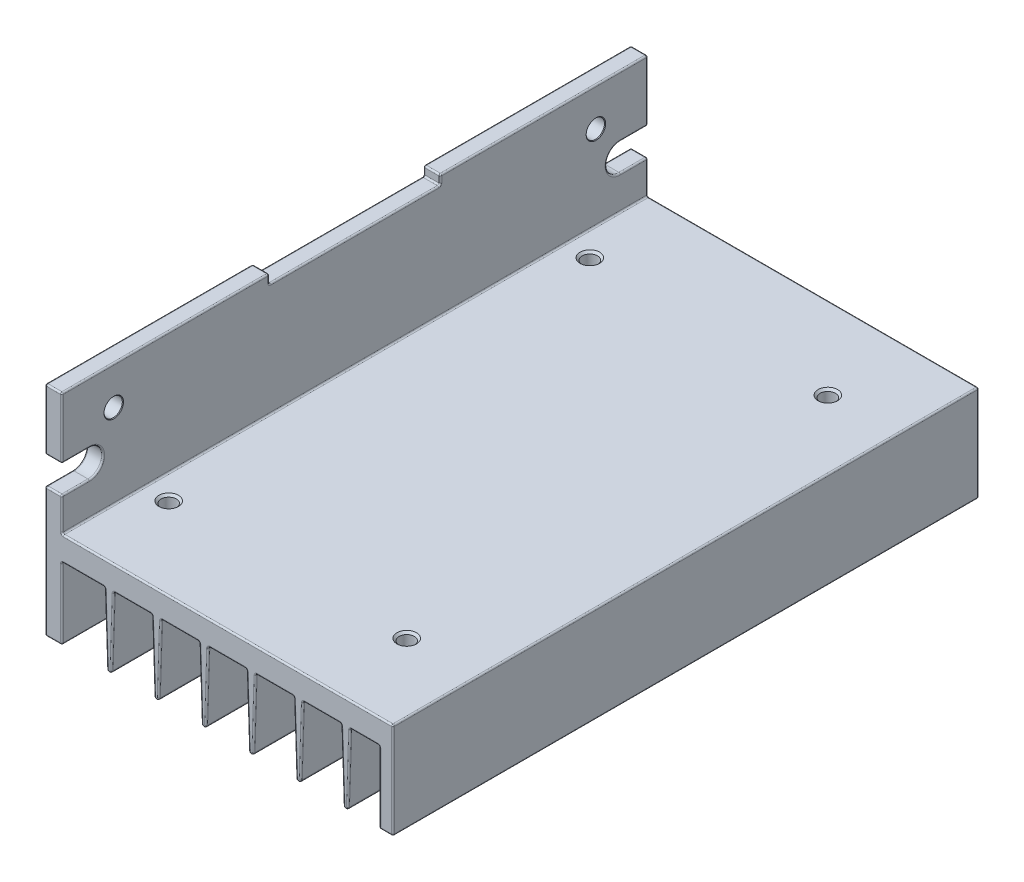
from build123d import *

# Parameters (mm, degrees)
BODY_DEPTH                  = 48
TOP_CUT_OUT_SKETCH_W        = 28
TOP_CUT_OUT_SKETCH_H        = 28
TOP_CUT_OUT_DEPTH           = 1.5
SIDE_CUT_OUT_DEPTH          = 3.75
M3_TOP_HOLES_AT_2_COUNT     = 2
M3_TOP_HOLES_AT_2_PITCH     = 69
M3_TOP_HOLES_AT_3_COUNT     = 2
M3_TOP_HOLES_AT_3_PITCH     = 79.259068882
M3_TOP_HOLES_AT_4_COUNT     = 2
M3_TOP_HOLES_AT_4_PITCH     = 39
F_3_0_SIDE_HOLES_AT_2_COUNT = 2
F_3_0_SIDE_HOLES_AT_2_PITCH = 79
PRODUCTION_FILLET_R         = 0.25


with BuildPart() as part:
    # Body Profile Sketch → Body (new body, symmetric)
    with BuildSketch(Plane.XY):
        with BuildLine():
            Line((0.25, 0), (54, 0))
            ThreePointArc((54, 0), (54.176776695, -0.073223305), (54.25, -0.25))
            Line((54.25, -0.25), (54.25, -15.5))
            ThreePointArc((54.25, -15.5), (54.176776695, -15.676776695), (54, -15.75))
            Line((54, -15.75), (52.25, -15.75))
            ThreePointArc((52.25, -15.75), (52.073223305, -15.676776695), (52, -15.5))
            Line((52, -15.5), (52, -4.25))
            ThreePointArc((52, -4.25), (51.926776695, -4.073223305), (51.75, -4))
            Line((51.75, -4), (47.491898383, -4))
            ThreePointArc((47.491898383, -4), (47.318056795, -4.070336141), (47.242033979, -4.241767182))
            Line((47.242033979, -4.241767182), (46.874796607, -15.387349227))
            ThreePointArc((46.874796607, -15.387349227), (46.5, -15.75), (46.125203393, -15.387349227))
            Line((46.125203393, -15.387349227), (45.757966021, -4.241767182))
            ThreePointArc((45.757966021, -4.241767182), (45.681943205, -4.070336141), (45.508101617, -4))
            Line((45.508101617, -4), (39.741898383, -4))
            ThreePointArc((39.741898383, -4), (39.568056795, -4.070336141), (39.492033979, -4.241767182))
            Line((39.492033979, -4.241767182), (39.124796607, -15.387349227))
            ThreePointArc((39.124796607, -15.387349227), (38.75, -15.75), (38.375203393, -15.387349227))
            Line((38.375203393, -15.387349227), (38.007966021, -4.241767182))
            ThreePointArc((38.007966021, -4.241767182), (37.931943205, -4.070336141), (37.758101617, -4))
            Line((37.758101617, -4), (31.991898383, -4))
            ThreePointArc((31.991898383, -4), (31.818056795, -4.070336141), (31.742033979, -4.241767182))
            Line((31.742033979, -4.241767182), (31.374796607, -15.387349227))
            ThreePointArc((31.374796607, -15.387349227), (31, -15.75), (30.625203393, -15.387349227))
            Line((30.625203393, -15.387349227), (30.257966021, -4.241767182))
            ThreePointArc((30.257966021, -4.241767182), (30.181943205, -4.070336141), (30.008101617, -4))
            Line((30.008101617, -4), (24.241898383, -4))
            ThreePointArc((24.241898383, -4), (24.068056795, -4.070336141), (23.992033979, -4.241767182))
            Line((23.992033979, -4.241767182), (23.624796607, -15.387349227))
            ThreePointArc((23.624796607, -15.387349227), (23.25, -15.75), (22.875203393, -15.387349227))
            Line((22.875203393, -15.387349227), (22.507966021, -4.241767182))
            ThreePointArc((22.507966021, -4.241767182), (22.431943205, -4.070336141), (22.258101617, -4))
            Line((22.258101617, -4), (16.491898383, -4))
            ThreePointArc((16.491898383, -4), (16.318056795, -4.070336141), (16.242033979, -4.241767182))
            Line((16.242033979, -4.241767182), (15.874796607, -15.387349227))
            ThreePointArc((15.874796607, -15.387349227), (15.5, -15.75), (15.125203393, -15.387349227))
            Line((15.125203393, -15.387349227), (14.757966021, -4.241767182))
            ThreePointArc((14.757966021, -4.241767182), (14.681943205, -4.070336141), (14.508101617, -4))
            Line((14.508101617, -4), (8.741898383, -4))
            ThreePointArc((8.741898383, -4), (8.568056795, -4.070336141), (8.492033979, -4.241767182))
            Line((8.492033979, -4.241767182), (8.124796607, -15.387349227))
            ThreePointArc((8.124796607, -15.387349227), (7.75, -15.75), (7.375203393, -15.387349227))
            Line((7.375203393, -15.387349227), (7.007966021, -4.241767182))
            ThreePointArc((7.007966021, -4.241767182), (6.931943205, -4.070336141), (6.758101617, -4))
            Line((6.758101617, -4), (0.25, -4))
            ThreePointArc((0.25, -4), (0.073223305, -4.073223305), (0, -4.25))
            Line((0, -4.25), (0, -15.5))
            ThreePointArc((0, -15.5), (-0.073223305, -15.676776695), (-0.25, -15.75))
            Line((-0.25, -15.75), (-2.5, -15.75))
            ThreePointArc((-2.5, -15.75), (-2.676776695, -15.676776695), (-2.75, -15.5))
            Line((-2.75, -15.5), (-2.75, 19.75))
            ThreePointArc((-2.75, 19.75), (-2.676776695, 19.926776695), (-2.5, 20))
            Line((-2.5, 20), (-0.25, 20))
            ThreePointArc((-0.25, 20), (-0.073223305, 19.926776695), (0, 19.75))
            Line((0, 19.75), (0, 0.25))
            ThreePointArc((0, 0.25), (0.073223305, 0.073223305), (0.25, 0))
        make_face()
    extrude(amount=BODY_DEPTH, both=True)

    # Top Cut Out Sketch → Top Cut Out (cut)
    with BuildSketch(Plane(origin=(0, 20, 0), x_dir=(1, 0, 0), z_dir=(0, 1, 0))):
        Rectangle(TOP_CUT_OUT_SKETCH_W, TOP_CUT_OUT_SKETCH_H)
    extrude(amount=-TOP_CUT_OUT_DEPTH, mode=Mode.SUBTRACT)

    # Side Cut Out Sketch → Side Cut Out (cut, through all)
    with BuildSketch(Plane(origin=(0, 0, 0), x_dir=(0, 0, -1), z_dir=(1, 0, 0))):
        with BuildLine():
            Line((48, 10), (43.5, 10))
            ThreePointArc((43.5, 10), (41.25, 7.75), (43.5, 5.5))
            Line((43.5, 5.5), (48, 5.5))
            Line((48, 5.5), (48, 10))
        make_face()
        with BuildLine():
            Line((-48, 10), (-43.5, 10))
            ThreePointArc((-43.5, 10), (-41.25, 7.75), (-43.5, 5.5))
            Line((-43.5, 5.5), (-48, 5.5))
            Line((-48, 5.5), (-48, 10))
        make_face()
    extrude(amount=-SIDE_CUT_OUT_DEPTH, mode=Mode.SUBTRACT)

    # Sketch4 → M3 Top Holes (revolve, cut)
    with BuildSketch(Plane(origin=(43, 0, -34.5), x_dir=(0, 0, 1), z_dir=(1, 0, 0))):
        Polygon((0, 0), (0, 4), (1.6, 4), (1.25, 3.65), (1.25, 0.35), (1.6, 0), align=None)
    m3_top_holes = revolve(axis=Axis((43, 6.35, -34.5), (0, -1, 0)), mode=Mode.SUBTRACT)

    # M3 Top Holes at 2: M3 Top Holes ×2
    with Locations(*[(0, 0, i * M3_TOP_HOLES_AT_2_PITCH) for i in range(1, M3_TOP_HOLES_AT_2_COUNT)]):
        add(m3_top_holes, mode=Mode.SUBTRACT)

    # M3 Top Holes at 3: M3 Top Holes ×2
    with Locations(*[Vector(-0.492057257, 0, 0.870562839) * (i * M3_TOP_HOLES_AT_3_PITCH) for i in range(1, M3_TOP_HOLES_AT_3_COUNT)]):
        add(m3_top_holes, mode=Mode.SUBTRACT)

    # M3 Top Holes at 4: M3 Top Holes ×2
    with Locations(*[(-i * M3_TOP_HOLES_AT_4_PITCH, 0, 0) for i in range(1, M3_TOP_HOLES_AT_4_COUNT)]):
        add(m3_top_holes, mode=Mode.SUBTRACT)

    # Sketch6 → Ø3.0 Side Holes (revolve, cut)
    with BuildSketch(Plane(origin=(0, 13.75, -39.5), x_dir=(0, 0, -1), z_dir=(0, 1, 0))):
        Polygon((0, 0), (0, 2.75), (1.6, 2.75), (1.5, 2.65), (1.5, 0.1), (1.6, 0), align=None)
    f_3_0_side_holes = revolve(axis=Axis((6.35, 13.75, -39.5), (-1, 0, 0)), mode=Mode.SUBTRACT)

    # Ø3.0 Side Holes at 2: Ø3.0 Side Holes ×2
    with Locations(*[(0, 0, i * F_3_0_SIDE_HOLES_AT_2_PITCH) for i in range(1, F_3_0_SIDE_HOLES_AT_2_COUNT)]):
        add(f_3_0_side_holes, mode=Mode.SUBTRACT)

    # Production Fillet
    production_fillet_edges = [part.edges().sort_by_distance(p)[0] for p in [
        (-1.375, 20, -14),
        (-0.073223305, 19.926776695, -14),
        (-2.676776695, 19.926776695, -14),
        (-0.073223305, 19.926776695, 14),
        (-2.676776695, 19.926776695, 14),
        (0, 19.125, -14),
        (-2.75, 19.125, -14),
        (0, 19.125, 14),
        (-2.75, 19.125, 14),
        (-2.75, 10, -45.75),
        (-2.75, 7.75, -41.25),
        (0, 10, -45.75),
        (0, 7.75, -41.25),
        (-2.75, 10, 45.75),
        (-2.75, 7.75, 41.25),
        (0, 10, 45.75),
        (0, 7.75, 41.25),
        (0, 2.875, 48),
        (0.073223305, 0.073223305, 48),
        (27.125, 0, 48),
        (54.176776695, -0.073223305, 48),
        (54.25, -7.875, 48),
        (54.176776695, -15.676776695, 48),
        (53.125, -15.75, 48),
        (52.073223305, -15.676776695, 48),
        (52, -9.875, 48),
        (51.926776695, -4.073223305, 48),
        (49.620949192, -4, 48),
        (47.318056795, -4.070336141, 48),
        (46.5, -15.75, 48),
        (45.941584707, -9.814558204, 48),
        (45.681943205, -4.070336141, 48),
        (39.568056795, -4.070336141, 48),
        (38.191584707, -9.814558204, 48),
        (34.875, -4, 48),
        (31.818056795, -4.070336141, 48),
        (31.558415293, -9.814558204, 48),
        (31, -15.75, 48),
        (30.441584707, -9.814558204, 48),
        (27.125, -4, 48),
        (24.068056795, -4.070336141, 48),
        (23.808415293, -9.814558204, 48),
        (23.25, -15.75, 48),
        (22.691584707, -9.814558204, 48),
        (22.431943205, -4.070336141, 48),
        (19.375, -4, 48),
        (16.318056795, -4.070336141, 48),
        (16.058415293, -9.814558204, 48),
        (15.5, -15.75, 48),
        (14.941584707, -9.814558204, 48),
        (14.681943205, -4.070336141, 48),
        (11.625, -4, 48),
        (8.568056795, -4.070336141, 48),
        (8.308415293, -9.814558204, 48),
        (7.191584707, -9.814558204, 48),
        (6.931943205, -4.070336141, 48),
        (0.073223305, -4.073223305, 48),
        (0, -9.875, 48),
        (-0.073223305, -15.676776695, 48),
        (-1.375, -15.75, 48),
        (-2.676776695, -15.676776695, 48),
        (-2.75, -5, -48),
        (-1.375, -15.75, -48),
        (-0.073223305, -15.676776695, -48),
        (0, -9.875, -48),
        (0.073223305, -4.073223305, -48),
        (3.504050808, -4, -48),
        (6.931943205, -4.070336141, -48),
        (7.191584707, -9.814558204, -48),
        (7.75, -15.75, -48),
        (8.568056795, -4.070336141, -48),
        (11.625, -4, -48),
        (14.681943205, -4.070336141, -48),
        (14.941584707, -9.814558204, -48),
        (15.5, -15.75, -48),
        (16.058415293, -9.814558204, -48),
        (16.318056795, -4.070336141, -48),
        (19.375, -4, -48),
        (22.431943205, -4.070336141, -48),
        (22.691584707, -9.814558204, -48),
        (23.25, -15.75, -48),
        (23.808415293, -9.814558204, -48),
        (24.068056795, -4.070336141, -48),
        (27.125, -4, -48),
        (30.181943205, -4.070336141, -48),
        (31, -15.75, -48),
        (31.558415293, -9.814558204, -48),
        (34.875, -4, -48),
        (38.75, -15.75, -48),
        (39.308415293, -9.814558204, -48),
        (39.568056795, -4.070336141, -48),
        (42.625, -4, -48),
        (45.681943205, -4.070336141, -48),
        (45.941584707, -9.814558204, -48),
        (46.5, -15.75, -48),
        (47.318056795, -4.070336141, -48),
        (51.926776695, -4.073223305, -48),
        (52, -9.875, -48),
        (52.073223305, -15.676776695, -48),
        (53.125, -15.75, -48),
        (54.176776695, -15.676776695, -48),
        (54.25, -7.875, -48),
        (54.176776695, -0.073223305, -48),
        (27.125, 0, -48),
        (0, 2.875, -48),
        (-2.75, 5.5, -45.75),
        (-1.375, 5.5, -48),
        (0, 5.5, -45.75),
        (0, 14.875, -48),
        (-0.073223305, 19.926776695, -48),
        (-1.375, 20, -48),
        (-2.75, 14.875, -48),
        (-1.375, 10, -48),
        (-1.375, 5.5, 48),
        (-2.676776695, 19.926776695, 48),
        (-1.375, 20, 48),
        (0, 14.875, 48),
        (-1.375, 10, 48),
        (-2.75, 14.875, 48),
        (-1.375, 18.5, -14),
        (0, 18.5, 0),
        (-1.375, 18.5, 14),
        (-2.75, 18.5, 0),
        (-2.75, -5, 48),
    ]]
    fillet(production_fillet_edges, radius=PRODUCTION_FILLET_R)


solid = part.part
